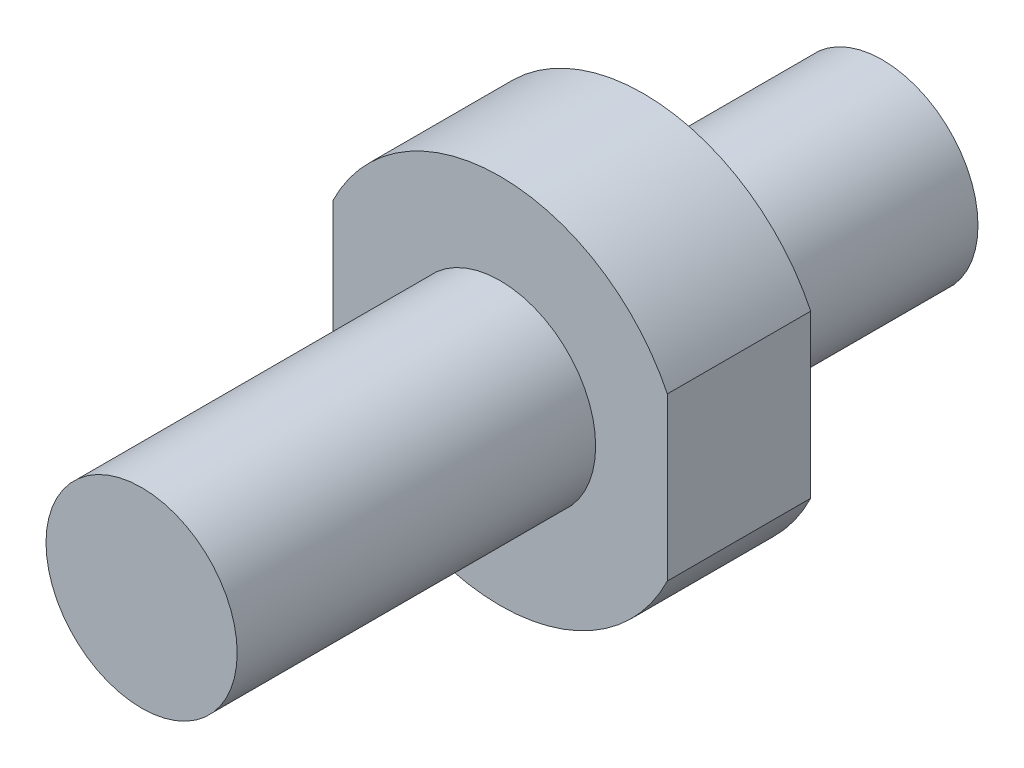
from build123d import *

# Parameters (mm, degrees)
SKETCH_3_W             = 8
SKETCH_3_H             = 16.823898374
CUT_EXTRUDE_1_DEPTH    = 10
HOLE_WIZARD_M4_1_D     = 3.3
HOLE_WIZARD_M4_1_DEPTH = 11.5
HOLE_WIZARD_M4_1_TIP   = 0.991420021
SKETCH_5_OUTSIDE_W     = 23.696
SKETCH_5_OUTSIDE_H     = 27.696
SKETCH_5_OUTSIDE_R     = 7.77784742
CUT_EXTRUDE_2_DEPTH    = 10


with BuildPart() as part:
    # 草图2 → 旋转1 (revolve)
    with BuildSketch(Plane(origin=(0, 0, 0), x_dir=(0, 0, -1), z_dir=(1, 0, 0))):
        Polygon((0, 0), (0, 4), (15, 4), (15, 9), (21, 9), (21, 4), (31, 4), (31, 0), align=None)
    revolve(axis=Axis((0, 0, 0), (0, 0, -1)))

    # 草图3 → 切除-拉伸1 (cut)
    with BuildSketch(Plane.XY.offset(-15)):
        with Locations((-11, -0.026043186)):
            Rectangle(SKETCH_3_W, SKETCH_3_H)
        with Locations((11, -0.026043186)):
            Rectangle(SKETCH_3_W, SKETCH_3_H)
    extrude(amount=-CUT_EXTRUDE_1_DEPTH, mode=Mode.SUBTRACT)

    # M4 螺纹孔1
    with Locations(Plane(origin=(0, 0, -31), x_dir=(-1, 0, 0), z_dir=(0, 0, -1))):
        with Locations((0, 0)):
            Hole(HOLE_WIZARD_M4_1_D / 2, depth=HOLE_WIZARD_M4_1_DEPTH)
            with Locations((0, 0, -(HOLE_WIZARD_M4_1_DEPTH + HOLE_WIZARD_M4_1_TIP / 2))):  # 118° drill point
                Cone(0, HOLE_WIZARD_M4_1_D / 2, HOLE_WIZARD_M4_1_TIP, mode=Mode.SUBTRACT)

    # 草图5 outside → 切除-拉伸2 (cut)
    with BuildSketch(Plane(origin=(0, 0, -21), x_dir=(-1, 0, 0), z_dir=(0, 0, -1))):
        Rectangle(SKETCH_5_OUTSIDE_W, SKETCH_5_OUTSIDE_H)
        Circle(SKETCH_5_OUTSIDE_R, mode=Mode.SUBTRACT)
    extrude(amount=-CUT_EXTRUDE_2_DEPTH, mode=Mode.SUBTRACT)


solid = part.part
